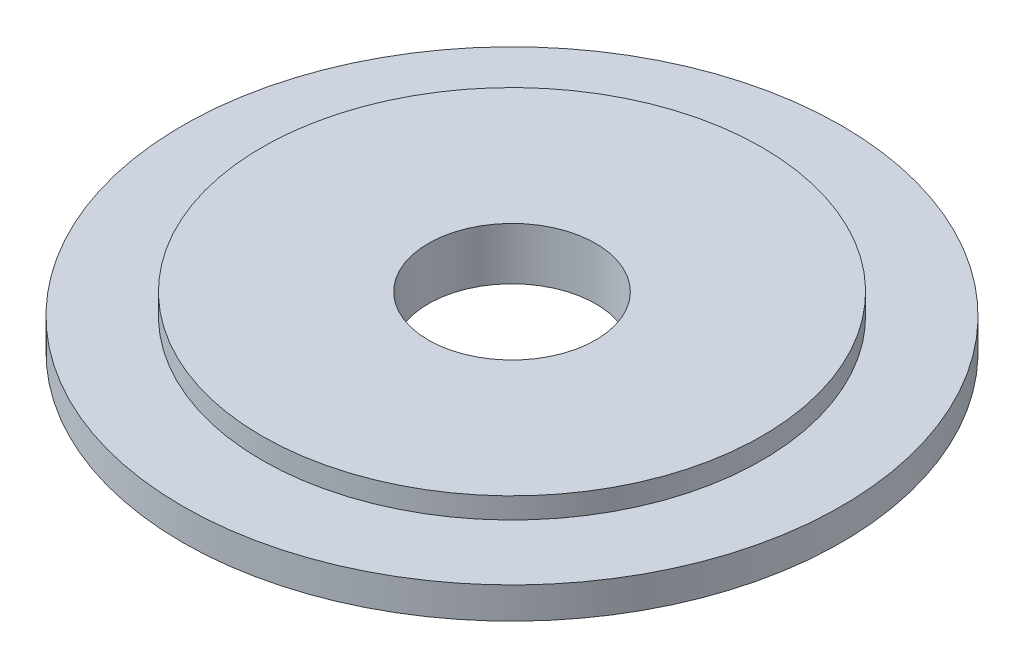
from build123d import *

# Parameters (mm, degrees)
CROQUIS1_R              = 23.9
CROQUIS1_R_2            = 8
SALIENTE_EXTRUIR1_DEPTH = 2
SALIENTE_EXTRUIR2_START = -3
CROQUIS1_3_R            = 31.5
CROQUIS1_3_R_2          = 8
SALIENTE_EXTRUIR2_DEPTH = 3


with BuildPart() as part:
    # Croquis1 → Saliente-Extruir1 (new body)
    with BuildSketch(Plane(origin=(0, 0, 0), x_dir=(1, 0, 0), z_dir=(0, 1, 0))):
        Circle(CROQUIS1_R)
        Circle(CROQUIS1_R_2, mode=Mode.SUBTRACT)
    extrude(amount=SALIENTE_EXTRUIR1_DEPTH)

    # Croquis1_3 → Saliente-Extruir2 (add)
    with BuildSketch(Plane(origin=(0, 0, 0), x_dir=(1, 0, 0), z_dir=(0, 1, 0)).offset(SALIENTE_EXTRUIR2_START)):
        Circle(CROQUIS1_3_R)
        Circle(CROQUIS1_3_R_2, mode=Mode.SUBTRACT)
    extrude(amount=SALIENTE_EXTRUIR2_DEPTH)


solid = part.part
